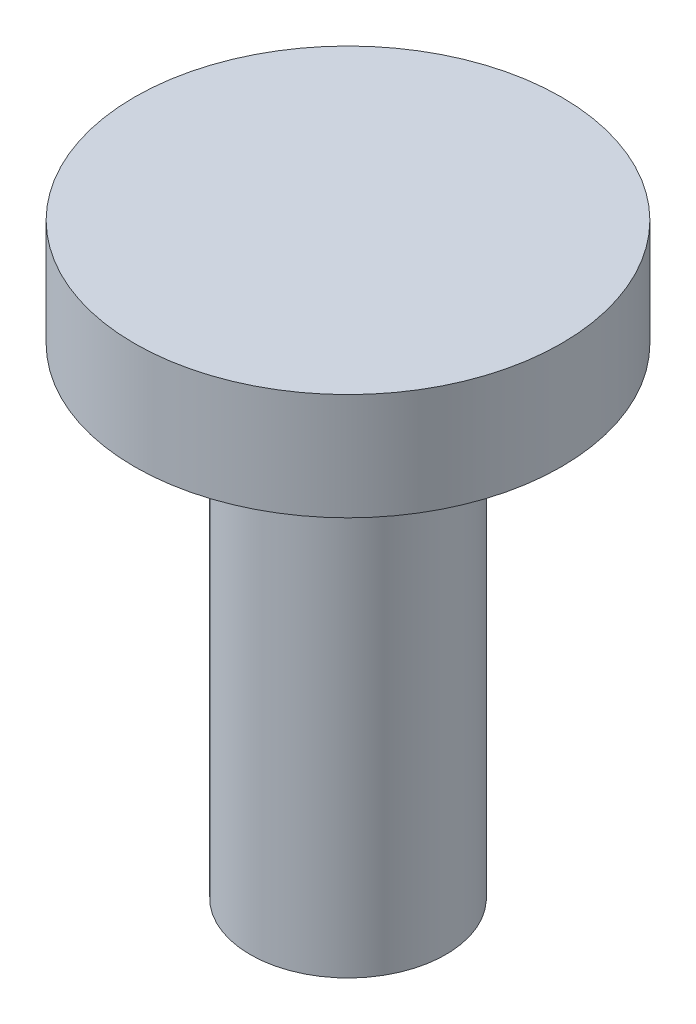
from build123d import *

# Parameters (mm, degrees)
SKETCH1_R           = 10
BOSS_EXTRUDE1_DEPTH = 45
SCALE_1_SCALE       = 0.3
SKETCH_1_R          = 6
EXTRUDE_1_DEPTH     = 3
SKETCH_2_R          = 3
SKETCH_2_R_2        = 2.75
CUT_EXTRUDE_1_DEPTH = 13.5


with BuildPart() as part:
    # Sketch1 → Boss-Extrude1 (new body)
    with BuildSketch(Plane(origin=(0, 0, 0), x_dir=(1, 0, 0), z_dir=(0, 1, 0))):
        Circle(SKETCH1_R)
    extrude(amount=BOSS_EXTRUDE1_DEPTH)


with BuildPart() as part_1:
    # 축척1: scaled about (0, 22.5, 0)
    add(part.part.scale(SCALE_1_SCALE).moved(Location((0, 15.75, 0))))

    # 스케치1 → 보스-돌출1 (add)
    with BuildSketch(Plane(origin=(0, 29.25, 0), x_dir=(1, 0, 0), z_dir=(0, 1, 0))):
        Circle(SKETCH_1_R)
    extrude(amount=EXTRUDE_1_DEPTH)

    # 스케치2 → 컷-돌출1 (cut)
    with BuildSketch(Plane.XZ.offset(-15.75)):
        Circle(SKETCH_2_R)
        Circle(SKETCH_2_R_2, mode=Mode.SUBTRACT)
    extrude(amount=-CUT_EXTRUDE_1_DEPTH, mode=Mode.SUBTRACT)


solid = part_1.part
